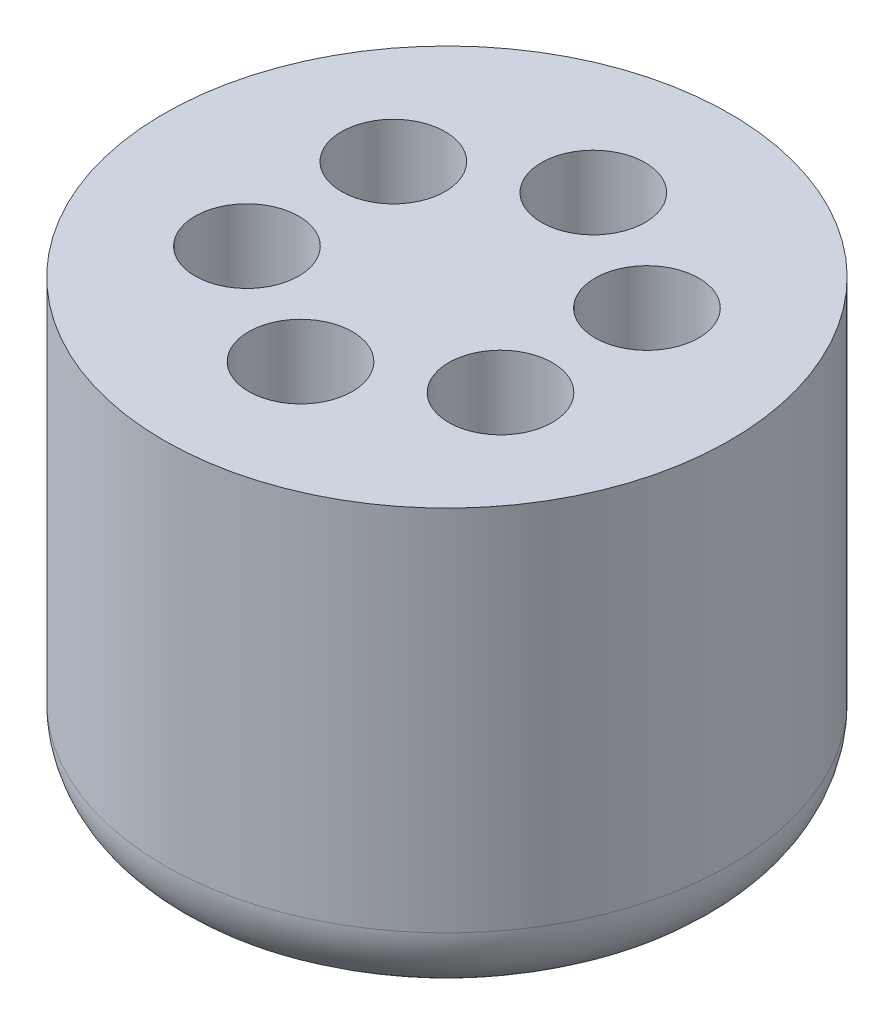
from build123d import *

# Parameters (mm, degrees)
SKETCH1_R           = 30
BOSS_EXTRUDE1_DEPTH = 47
SKETCH2_R           = 5.5
CUT_EXTRUDE1_DEPTH  = 32
FILLET1_R           = 8
SKETCH2_3_R         = 5.5
CUT_EXTRUDE2_DEPTH  = 35


with BuildPart() as part:
    # Sketch1 → Boss-Extrude1 (new body)
    with BuildSketch(Plane(origin=(0, 0, 0), x_dir=(1, 0, 0), z_dir=(0, 1, 0))):
        Circle(SKETCH1_R)
    extrude(amount=BOSS_EXTRUDE1_DEPTH)

    # Sketch2 → Cut-Extrude1 (cut)
    with BuildSketch(Plane(origin=(0, 47, 0), x_dir=(1, 0, 0), z_dir=(0, 1, 0))):
        with Locations((0, 15.52)):
            Circle(SKETCH2_R)
        with Locations((-13.440714267, 7.76)):
            Circle(SKETCH2_R)
        with Locations((-13.440714267, -7.76)):
            Circle(SKETCH2_R)
        with Locations((0, -15.52)):
            Circle(SKETCH2_R)
        with Locations((13.440714267, -7.76)):
            Circle(SKETCH2_R)
        with Locations((13.440714267, 7.76)):
            Circle(SKETCH2_R)
    extrude(amount=-CUT_EXTRUDE1_DEPTH, mode=Mode.SUBTRACT)

    # Fillet1
    fillet1_edges = [part.edges().sort_by_distance(p)[0] for p in [
        (-30, 0, 0),
    ]]
    fillet(fillet1_edges, radius=FILLET1_R)

    # Sketch2_3 → Cut-Extrude2 (cut)
    with BuildSketch(Plane(origin=(0, 47, 0), x_dir=(1, 0, 0), z_dir=(0, 1, 0))):
        with Locations((0, 15.52)):
            Circle(SKETCH2_3_R)
        with Locations((-13.440714267, 7.76)):
            Circle(SKETCH2_3_R)
        with Locations((-13.440714267, -7.76)):
            Circle(SKETCH2_3_R)
        with Locations((0, -15.52)):
            Circle(SKETCH2_3_R)
        with Locations((13.440714267, -7.76)):
            Circle(SKETCH2_3_R)
        with Locations((13.440714267, 7.76)):
            Circle(SKETCH2_3_R)
    extrude(amount=-CUT_EXTRUDE2_DEPTH, mode=Mode.SUBTRACT)


solid = part.part
